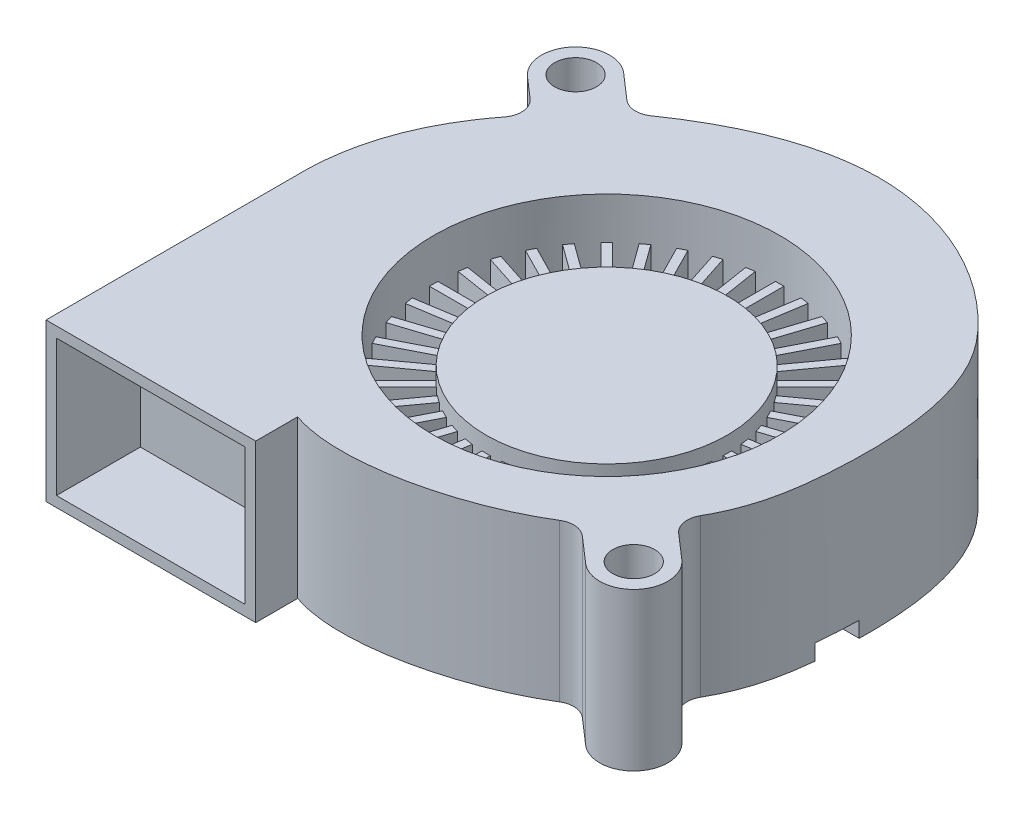
from build123d import *

# Parameters (mm, degrees)
SKETCH1_R           = 2
SKETCH1_R_2         = 16.5
BOSS_EXTRUDE1_DEPTH = 15
SKETCH1_3_R         = 11.5
BOSS_EXTRUDE2_DEPTH = 12.5
SKETCH1_4_R         = 16.5
SKETCH1_4_R_2       = 11.5
BOSS_EXTRUDE3_DEPTH = 7
BOSS_EXTRUDE4_DEPTH = 4
SKETCH3_W           = 18
SKETCH3_H           = 13
CUT_EXTRUDE1_DEPTH  = 8
CUT_EXTRUDE2_DEPTH  = 1.5
FILLET1_R           = 2


with BuildPart() as part:
    # Sketch1 → Boss-Extrude1 (new body)
    with BuildSketch(Plane(origin=(0, 0, 0), x_dir=(1, 0, 0), z_dir=(0, 1, 0))):
        with BuildLine():
            Line((-28, -0.468774376), (-28, -25.468774376))
            Line((-28, -25.468774376), (-8, -25.468774376))
            Line((-8, -25.468774376), (-8, -21.468774376))
            add(Edge.make_bspline(
                [(14.253356191, -16.72335625), (8.341566518, -20.938444001), (-2.141576122, -23.549225207), (-8, -21.468774376)],
                knots=[0.819888366, 0.819888366, 0.819888366, 0.819888366, 1, 1, 1, 1], degree=3))
            Line((14.253356191, -16.72335625), (17.849131696, -19.854999313))
            ThreePointArc((17.849131696, -19.854999313), (22.43442623, -19.538654502), (22.118081419, -14.953359968))
            Line((22.118081419, -14.953359968), (18.496044357, -11.798845116))
            add(Edge.make_bspline(
                [(-17.253966618, 19.336656445), (-13.100556357, 22.458304138), (-6.58434708, 25.982242177), (5.234062645, 26.065265062), (12.91629158, 22.905181486), (21.860855364, 13.201527624), (22.588257288, 0.087187395), (21.062574588, -8.107059206), (18.496044357, -11.798845116)],
                knots=[0.198947602, 0.198947602, 0.198947602, 0.198947602, 0.358848222, 0.392677004, 0.521173371, 0.550310226, 0.667983506, 0.765325526, 0.765325526, 0.765325526, 0.765325526], degree=3))
            Line((-17.253966618, 19.336656445), (-20.865525138, 22.482045296))
            ThreePointArc((-20.865525138, 22.482045296), (-25.450819672, 22.165700486), (-25.134474862, 17.580405952))
            Line((-25.134474862, 17.580405952), (-21.708688764, 14.596810549))
            add(Edge.make_bspline(
                [(-28, -0.468774376), (-27.749791137, 7.736228001), (-21.708688764, 14.596810549)],
                knots=[0, 0, 0, 0.146640689, 0.146640689, 0.146640689], degree=2))
        make_face()
        with Locations((19.983606557, -17.404179641)):
            Circle(SKETCH1_R, mode=Mode.SUBTRACT)
        Circle(SKETCH1_R_2, mode=Mode.SUBTRACT)
        with Locations((-23, 20.031225624)):
            Circle(SKETCH1_R, mode=Mode.SUBTRACT)
    extrude(amount=BOSS_EXTRUDE1_DEPTH)



with BuildPart() as body_2:
    # Sketch1_3 → Boss-Extrude2 (new body)
    with BuildSketch(Plane(origin=(0, 0, 0), x_dir=(1, 0, 0), z_dir=(0, 1, 0))):
        Circle(SKETCH1_3_R)
    extrude(amount=BOSS_EXTRUDE2_DEPTH)


with BuildPart() as part_1:
    add(part.part)

    add(body_2.part)  # Boss-Extrude3 merges body 2
    # Sketch1_4 → Boss-Extrude3 (add)
    with BuildSketch(Plane(origin=(0, 0, 0), x_dir=(1, 0, 0), z_dir=(0, 1, 0))):
        Circle(SKETCH1_4_R)
        Circle(SKETCH1_4_R_2, mode=Mode.SUBTRACT)
    extrude(amount=BOSS_EXTRUDE3_DEPTH)

    # Sketch2 → Boss-Extrude4 (add)
    with BuildSketch(Plane(origin=(0, 7, 0), x_dir=(1, 0, 0), z_dir=(0, 1, 0))):
        with BuildLine():
            Line((-0.4, 11.493041373), (-0.4, 16.495150803))
            ThreePointArc((-0.4, 16.495150803), (0, 16.5), (0.4, 16.495150803))
            Line((0.4, 16.495150803), (0.4, 11.493041373))
            ThreePointArc((0.4, 11.493041373), (0, 11.5), (-0.4, 11.493041373))
        make_face()
        with BuildLine():
            Line((2.975485428, 16.229494338), (2.192983115, 11.288969176))
            ThreePointArc((2.192983115, 11.288969176), (1.798996348, 11.358415917), (1.402832443, 11.414116748))
            Line((1.402832443, 11.414116748), (2.185334755, 16.35464191))
            ThreePointArc((2.185334755, 16.35464191), (2.581168673, 16.29685762), (2.975485428, 16.229494338))
        make_face()
        with BuildLine():
            Line((5.477704529, 15.56421386), (3.931967708, 10.806925092))
            ThreePointArc((3.931967708, 10.806925092), (3.553695435, 10.937149937), (3.171122495, 11.054138688))
            Line((3.171122495, 11.054138688), (4.716859316, 15.811427456))
            ThreePointArc((4.716859316, 15.811427456), (5.098780407, 15.692432519), (5.477704529, 15.56421386))
        make_face()
        with BuildLine():
            Line((7.845044366, 14.515690783), (5.574134206, 10.058778646))
            ThreePointArc((5.574134206, 10.058778646), (5.220890747, 10.246575028), (4.861328987, 10.421971046))
            Line((4.861328987, 10.421971046), (7.132239146, 14.878883182))
            ThreePointArc((7.132239146, 14.878883182), (7.490843246, 14.701607649), (7.845044366, 14.515690783))
        make_face()
        with BuildLine():
            Line((10.019213174, 13.109743223), (7.079047021, 9.062951687))
            ThreePointArc((7.079047021, 9.062951687), (6.759530401, 9.303695435), (6.431833425, 9.533179889))
            Line((6.431833425, 9.533179889), (9.371999578, 13.579971425))
            ThreePointArc((9.371999578, 13.579971425), (9.698456663, 13.348780407), (10.019213174, 13.109743223))
        make_face()
        with BuildLine():
            Line((11.946675702, 11.380990277), (8.409650204, 7.843964779))
            ThreePointArc((8.409650204, 7.843964779), (8.131727984, 8.131727984), (7.843964779, 8.409650204))
            Line((7.843964779, 8.409650204), (11.380990277, 11.946675702))
            ThreePointArc((11.380990277, 11.946675702), (11.66726189, 11.66726189), (11.946675702, 11.380990277))
        make_face()
        with BuildLine():
            Line((13.579971425, 9.371999578), (9.533179889, 6.431833425))
            ThreePointArc((9.533179889, 6.431833425), (9.303695435, 6.759530401), (9.062951687, 7.079047021))
            Line((9.062951687, 7.079047021), (13.109743223, 10.019213174))
            ThreePointArc((13.109743223, 10.019213174), (13.348780407, 9.698456663), (13.579971425, 9.371999578))
        make_face()
        with BuildLine():
            Line((14.878883182, 7.132239146), (10.421971046, 4.861328987))
            ThreePointArc((10.421971046, 4.861328987), (10.246575028, 5.220890747), (10.058778646, 5.574134206))
            Line((10.058778646, 5.574134206), (14.515690783, 7.845044366))
            ThreePointArc((14.515690783, 7.845044366), (14.701607649, 7.490843246), (14.878883182, 7.132239146))
        make_face()
        with BuildLine():
            Line((15.811427456, 4.716859316), (11.054138688, 3.171122495))
            ThreePointArc((11.054138688, 3.171122495), (10.937149937, 3.553695435), (10.806925092, 3.931967708))
            Line((10.806925092, 3.931967708), (15.56421386, 5.477704529))
            ThreePointArc((15.56421386, 5.477704529), (15.692432519, 5.098780407), (15.811427456, 4.716859316))
        make_face()
        with BuildLine():
            Line((16.35464191, 2.185334755), (11.414116748, 1.402832443))
            ThreePointArc((11.414116748, 1.402832443), (11.358415917, 1.798996348), (11.288969176, 2.192983115))
            Line((11.288969176, 2.192983115), (16.229494338, 2.975485428))
            ThreePointArc((16.229494338, 2.975485428), (16.29685762, 2.581168673), (16.35464191, 2.185334755))
        make_face()
        with BuildLine():
            Line((16.495150803, -0.4), (11.493041373, -0.4))
            ThreePointArc((11.493041373, -0.4), (11.5, 0), (11.493041373, 0.4))
            Line((11.493041373, 0.4), (16.495150803, 0.4))
            ThreePointArc((16.495150803, 0.4), (16.5, 0), (16.495150803, -0.4))
        make_face()
        with BuildLine():
            Line((16.229494338, -2.975485428), (11.288969176, -2.192983115))
            ThreePointArc((11.288969176, -2.192983115), (11.358415917, -1.798996348), (11.414116748, -1.402832443))
            Line((11.414116748, -1.402832443), (16.35464191, -2.185334755))
            ThreePointArc((16.35464191, -2.185334755), (16.29685762, -2.581168673), (16.229494338, -2.975485428))
        make_face()
        with BuildLine():
            Line((15.56421386, -5.477704529), (10.806925092, -3.931967708))
            ThreePointArc((10.806925092, -3.931967708), (10.937149937, -3.553695435), (11.054138688, -3.171122495))
            Line((11.054138688, -3.171122495), (15.811427456, -4.716859316))
            ThreePointArc((15.811427456, -4.716859316), (15.692432519, -5.098780407), (15.56421386, -5.477704529))
        make_face()
        with BuildLine():
            Line((14.515690783, -7.845044366), (10.058778646, -5.574134206))
            ThreePointArc((10.058778646, -5.574134206), (10.246575028, -5.220890747), (10.421971046, -4.861328987))
            Line((10.421971046, -4.861328987), (14.878883182, -7.132239146))
            ThreePointArc((14.878883182, -7.132239146), (14.701607649, -7.490843246), (14.515690783, -7.845044366))
        make_face()
        with BuildLine():
            Line((13.109743223, -10.019213174), (9.062951687, -7.079047021))
            ThreePointArc((9.062951687, -7.079047021), (9.303695435, -6.759530401), (9.533179889, -6.431833425))
            Line((9.533179889, -6.431833425), (13.579971425, -9.371999578))
            ThreePointArc((13.579971425, -9.371999578), (13.348780407, -9.698456663), (13.109743223, -10.019213174))
        make_face()
        with BuildLine():
            Line((11.380990277, -11.946675702), (7.843964779, -8.409650204))
            ThreePointArc((7.843964779, -8.409650204), (8.131727984, -8.131727984), (8.409650204, -7.843964779))
            Line((8.409650204, -7.843964779), (11.946675702, -11.380990277))
            ThreePointArc((11.946675702, -11.380990277), (11.66726189, -11.66726189), (11.380990277, -11.946675702))
        make_face()
        with BuildLine():
            Line((9.371999578, -13.579971425), (6.431833425, -9.533179889))
            ThreePointArc((6.431833425, -9.533179889), (6.759530401, -9.303695435), (7.079047021, -9.062951687))
            Line((7.079047021, -9.062951687), (10.019213174, -13.109743223))
            ThreePointArc((10.019213174, -13.109743223), (9.698456663, -13.348780407), (9.371999578, -13.579971425))
        make_face()
        with BuildLine():
            Line((7.132239146, -14.878883182), (4.861328987, -10.421971046))
            ThreePointArc((4.861328987, -10.421971046), (5.220890747, -10.246575028), (5.574134206, -10.058778646))
            Line((5.574134206, -10.058778646), (7.845044366, -14.515690783))
            ThreePointArc((7.845044366, -14.515690783), (7.490843246, -14.701607649), (7.132239146, -14.878883182))
        make_face()
        with BuildLine():
            Line((4.716859316, -15.811427456), (3.171122495, -11.054138688))
            ThreePointArc((3.171122495, -11.054138688), (3.553695435, -10.937149937), (3.931967708, -10.806925092))
            Line((3.931967708, -10.806925092), (5.477704529, -15.56421386))
            ThreePointArc((5.477704529, -15.56421386), (5.098780407, -15.692432519), (4.716859316, -15.811427456))
        make_face()
        with BuildLine():
            Line((2.185334755, -16.35464191), (1.402832443, -11.414116748))
            ThreePointArc((1.402832443, -11.414116748), (1.798996348, -11.358415917), (2.192983115, -11.288969176))
            Line((2.192983115, -11.288969176), (2.975485428, -16.229494338))
            ThreePointArc((2.975485428, -16.229494338), (2.581168673, -16.29685762), (2.185334755, -16.35464191))
        make_face()
        with BuildLine():
            Line((-0.4, -16.495150803), (-0.4, -11.493041373))
            ThreePointArc((-0.4, -11.493041373), (0, -11.5), (0.4, -11.493041373))
            Line((0.4, -11.493041373), (0.4, -16.495150803))
            ThreePointArc((0.4, -16.495150803), (0, -16.5), (-0.4, -16.495150803))
        make_face()
        with BuildLine():
            Line((-2.975485428, -16.229494338), (-2.192983115, -11.288969176))
            ThreePointArc((-2.192983115, -11.288969176), (-1.798996348, -11.358415917), (-1.402832443, -11.414116748))
            Line((-1.402832443, -11.414116748), (-2.185334755, -16.35464191))
            ThreePointArc((-2.185334755, -16.35464191), (-2.581168673, -16.29685762), (-2.975485428, -16.229494338))
        make_face()
        with BuildLine():
            Line((-5.477704529, -15.56421386), (-3.931967708, -10.806925092))
            ThreePointArc((-3.931967708, -10.806925092), (-3.553695435, -10.937149937), (-3.171122495, -11.054138688))
            Line((-3.171122495, -11.054138688), (-4.716859316, -15.811427456))
            ThreePointArc((-4.716859316, -15.811427456), (-5.098780407, -15.692432519), (-5.477704529, -15.56421386))
        make_face()
        with BuildLine():
            Line((-7.845044366, -14.515690783), (-5.574134206, -10.058778646))
            ThreePointArc((-5.574134206, -10.058778646), (-5.220890747, -10.246575028), (-4.861328987, -10.421971046))
            Line((-4.861328987, -10.421971046), (-7.132239146, -14.878883182))
            ThreePointArc((-7.132239146, -14.878883182), (-7.490843246, -14.701607649), (-7.845044366, -14.515690783))
        make_face()
        with BuildLine():
            Line((-10.019213174, -13.109743223), (-7.079047021, -9.062951687))
            ThreePointArc((-7.079047021, -9.062951687), (-6.759530401, -9.303695435), (-6.431833425, -9.533179889))
            Line((-6.431833425, -9.533179889), (-9.371999578, -13.579971425))
            ThreePointArc((-9.371999578, -13.579971425), (-9.698456663, -13.348780407), (-10.019213174, -13.109743223))
        make_face()
        with BuildLine():
            Line((-11.946675702, -11.380990277), (-8.409650204, -7.843964779))
            ThreePointArc((-8.409650204, -7.843964779), (-8.131727984, -8.131727984), (-7.843964779, -8.409650204))
            Line((-7.843964779, -8.409650204), (-11.380990277, -11.946675702))
            ThreePointArc((-11.380990277, -11.946675702), (-11.66726189, -11.66726189), (-11.946675702, -11.380990277))
        make_face()
        with BuildLine():
            Line((-13.579971425, -9.371999578), (-9.533179889, -6.431833425))
            ThreePointArc((-9.533179889, -6.431833425), (-9.303695435, -6.759530401), (-9.062951687, -7.079047021))
            Line((-9.062951687, -7.079047021), (-13.109743223, -10.019213174))
            ThreePointArc((-13.109743223, -10.019213174), (-13.348780407, -9.698456663), (-13.579971425, -9.371999578))
        make_face()
        with BuildLine():
            Line((-14.878883182, -7.132239146), (-10.421971046, -4.861328987))
            ThreePointArc((-10.421971046, -4.861328987), (-10.246575028, -5.220890747), (-10.058778646, -5.574134206))
            Line((-10.058778646, -5.574134206), (-14.515690783, -7.845044366))
            ThreePointArc((-14.515690783, -7.845044366), (-14.701607649, -7.490843246), (-14.878883182, -7.132239146))
        make_face()
        with BuildLine():
            Line((-15.811427456, -4.716859316), (-11.054138688, -3.171122495))
            ThreePointArc((-11.054138688, -3.171122495), (-10.937149937, -3.553695435), (-10.806925092, -3.931967708))
            Line((-10.806925092, -3.931967708), (-15.56421386, -5.477704529))
            ThreePointArc((-15.56421386, -5.477704529), (-15.692432519, -5.098780407), (-15.811427456, -4.716859316))
        make_face()
        with BuildLine():
            Line((-16.35464191, -2.185334755), (-11.414116748, -1.402832443))
            ThreePointArc((-11.414116748, -1.402832443), (-11.358415917, -1.798996348), (-11.288969176, -2.192983115))
            Line((-11.288969176, -2.192983115), (-16.229494338, -2.975485428))
            ThreePointArc((-16.229494338, -2.975485428), (-16.29685762, -2.581168673), (-16.35464191, -2.185334755))
        make_face()
        with BuildLine():
            Line((-16.495150803, 0.4), (-11.493041373, 0.4))
            ThreePointArc((-11.493041373, 0.4), (-11.5, 0), (-11.493041373, -0.4))
            Line((-11.493041373, -0.4), (-16.495150803, -0.4))
            ThreePointArc((-16.495150803, -0.4), (-16.5, 0), (-16.495150803, 0.4))
        make_face()
        with BuildLine():
            Line((-16.229494338, 2.975485428), (-11.288969176, 2.192983115))
            ThreePointArc((-11.288969176, 2.192983115), (-11.358415917, 1.798996348), (-11.414116748, 1.402832443))
            Line((-11.414116748, 1.402832443), (-16.35464191, 2.185334755))
            ThreePointArc((-16.35464191, 2.185334755), (-16.29685762, 2.581168673), (-16.229494338, 2.975485428))
        make_face()
        with BuildLine():
            Line((-15.56421386, 5.477704529), (-10.806925092, 3.931967708))
            ThreePointArc((-10.806925092, 3.931967708), (-10.937149937, 3.553695435), (-11.054138688, 3.171122495))
            Line((-11.054138688, 3.171122495), (-15.811427456, 4.716859316))
            ThreePointArc((-15.811427456, 4.716859316), (-15.692432519, 5.098780407), (-15.56421386, 5.477704529))
        make_face()
        with BuildLine():
            Line((-14.515690783, 7.845044366), (-10.058778646, 5.574134206))
            ThreePointArc((-10.058778646, 5.574134206), (-10.246575028, 5.220890747), (-10.421971046, 4.861328987))
            Line((-10.421971046, 4.861328987), (-14.878883182, 7.132239146))
            ThreePointArc((-14.878883182, 7.132239146), (-14.701607649, 7.490843246), (-14.515690783, 7.845044366))
        make_face()
        with BuildLine():
            Line((-13.109743223, 10.019213174), (-9.062951687, 7.079047021))
            ThreePointArc((-9.062951687, 7.079047021), (-9.303695435, 6.759530401), (-9.533179889, 6.431833425))
            Line((-9.533179889, 6.431833425), (-13.579971425, 9.371999578))
            ThreePointArc((-13.579971425, 9.371999578), (-13.348780407, 9.698456663), (-13.109743223, 10.019213174))
        make_face()
        with BuildLine():
            Line((-11.380990277, 11.946675702), (-7.843964779, 8.409650204))
            ThreePointArc((-7.843964779, 8.409650204), (-8.131727984, 8.131727984), (-8.409650204, 7.843964779))
            Line((-8.409650204, 7.843964779), (-11.946675702, 11.380990277))
            ThreePointArc((-11.946675702, 11.380990277), (-11.66726189, 11.66726189), (-11.380990277, 11.946675702))
        make_face()
        with BuildLine():
            Line((-9.371999578, 13.579971425), (-6.431833425, 9.533179889))
            ThreePointArc((-6.431833425, 9.533179889), (-6.759530401, 9.303695435), (-7.079047021, 9.062951687))
            Line((-7.079047021, 9.062951687), (-10.019213174, 13.109743223))
            ThreePointArc((-10.019213174, 13.109743223), (-9.698456663, 13.348780407), (-9.371999578, 13.579971425))
        make_face()
        with BuildLine():
            Line((-7.132239146, 14.878883182), (-4.861328987, 10.421971046))
            ThreePointArc((-4.861328987, 10.421971046), (-5.220890747, 10.246575028), (-5.574134206, 10.058778646))
            Line((-5.574134206, 10.058778646), (-7.845044366, 14.515690783))
            ThreePointArc((-7.845044366, 14.515690783), (-7.490843246, 14.701607649), (-7.132239146, 14.878883182))
        make_face()
        with BuildLine():
            Line((-4.716859316, 15.811427456), (-3.171122495, 11.054138688))
            ThreePointArc((-3.171122495, 11.054138688), (-3.553695435, 10.937149937), (-3.931967708, 10.806925092))
            Line((-3.931967708, 10.806925092), (-5.477704529, 15.56421386))
            ThreePointArc((-5.477704529, 15.56421386), (-5.098780407, 15.692432519), (-4.716859316, 15.811427456))
        make_face()
        with BuildLine():
            Line((-2.185334755, 16.35464191), (-1.402832443, 11.414116748))
            ThreePointArc((-1.402832443, 11.414116748), (-1.798996348, 11.358415917), (-2.192983115, 11.288969176))
            Line((-2.192983115, 11.288969176), (-2.975485428, 16.229494338))
            ThreePointArc((-2.975485428, 16.229494338), (-2.581168673, 16.29685762), (-2.185334755, 16.35464191))
        make_face()
    extrude(amount=BOSS_EXTRUDE4_DEPTH)

    # Sketch3 → Cut-Extrude1 (cut)
    with BuildSketch(Plane.XY.offset(25.468774376)):
        with Locations((-18, 7.5)):
            Rectangle(SKETCH3_W, SKETCH3_H)
    extrude(amount=-CUT_EXTRUDE1_DEPTH, mode=Mode.SUBTRACT)

    # Sketch4 → Cut-Extrude2 (cut)
    with BuildSketch(Plane.XZ):
        with BuildLine():
            Line((21.848075566, 1.996381685), (16.848075566, 1.999999476))
            Line((16.848075566, 1.999999476), (16.845181334, -1.999999476))
            Line((16.845181334, -1.999999476), (22.076666213, -2.00378476))
            add(Edge.make_bspline(
                [(22.076666213, -2.00378476), (22.063598838, -1.324043699), (22.008735374, 0.042572827), (21.912917026, 1.345760088), (21.848075566, 1.996381685)],
                knots=[0.653497202, 0.653497202, 0.653497202, 0.653497202, 0.667983506, 0.683061339, 0.683061339, 0.683061339, 0.683061339], degree=3))
        make_face()
    extrude(amount=-CUT_EXTRUDE2_DEPTH, mode=Mode.SUBTRACT)

    # Fillet1
    fillet1_edges = [part_1.edges().sort_by_distance(p)[0] for p in [
        (14.253356191, 7.5, 16.72335625),
        (18.496044357, 7.5, 11.798845116),
        (-17.253966618, 7.5, -19.336656445),
        (-21.708688764, 7.5, -14.596810549),
    ]]
    fillet(fillet1_edges, radius=FILLET1_R)


solid = part_1.part
